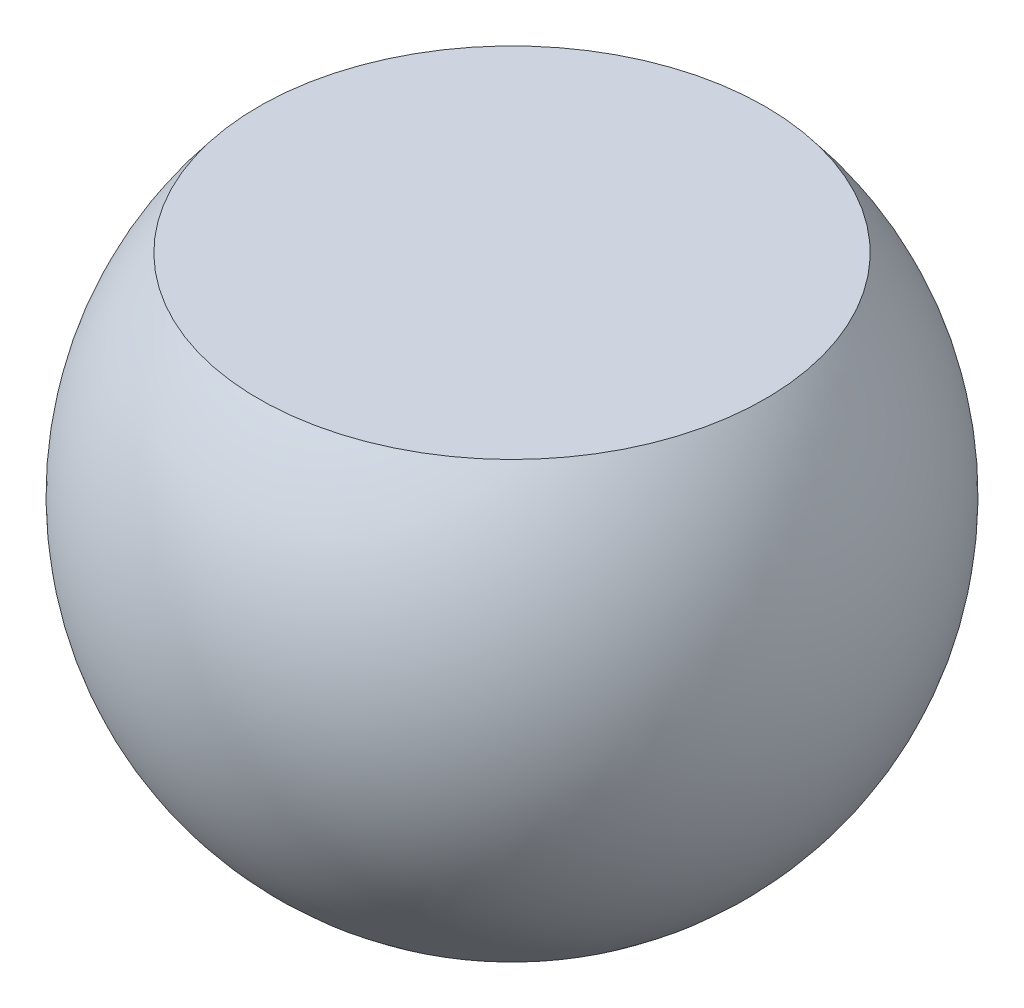
from build123d import *

# Parameters (mm, degrees)
SKETCH3_W          = 8.432018594
SKETCH3_H          = 8.257563036
CUT_EXTRUDE1_DEPTH = 2.54


with BuildPart() as part:
    # Sketch1 → Revolve2 (revolve)
    with BuildSketch(Plane(origin=(0, 0, 0), x_dir=(1, 0, 0), z_dir=(0, 1, 0))):
        with BuildLine():
            Line((0, 3.37), (0, -3.37))
            ThreePointArc((0, -3.37), (-3.37, 0), (0, 3.37))
        make_face()
    revolve(axis=Axis((0, 0, -3.37), (0, 0, 1)))

    # Sketch3 → Cut-Extrude1 (cut)
    with BuildSketch(Plane(origin=(0, 2.156000006, 0), x_dir=(1, 0, 0), z_dir=(0, 1, 0))):
        Rectangle(SKETCH3_W, SKETCH3_H)
    extrude(amount=CUT_EXTRUDE1_DEPTH, mode=Mode.SUBTRACT)


solid = part.part
